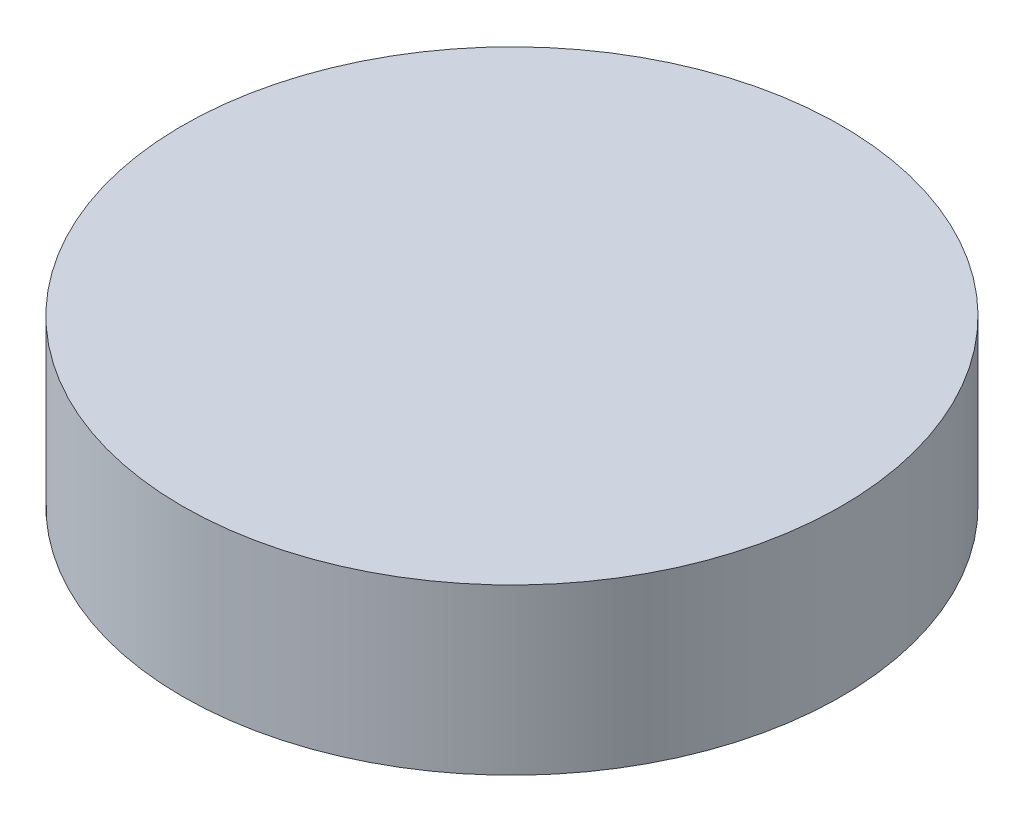
from build123d import *

# Parameters (mm, degrees)
SKETCH_1_R      = 20
EXTRUDE_1_DEPTH = 10


with BuildPart() as part:
    # Эскиз1 → Бобышка-Вытянуть1 (new body)
    with BuildSketch(Plane(origin=(0, 0, 0), x_dir=(1, 0, 0), z_dir=(0, 1, 0))):
        Circle(SKETCH_1_R)
    extrude(amount=EXTRUDE_1_DEPTH)


solid = part.part
